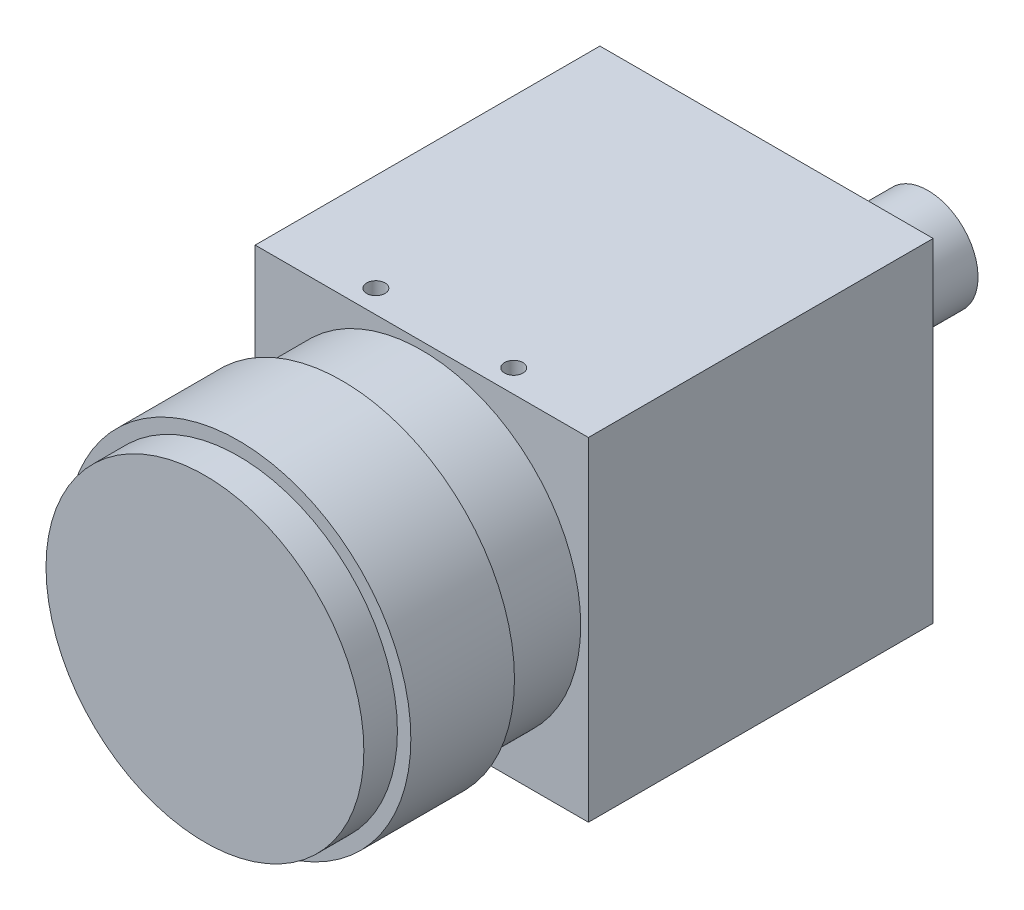
from build123d import *

# Parameters (mm, degrees)
SKETCH1_W                 = 29
SKETCH1_H                 = 29
BOSS_EXTRUDE1_DEPTH       = 30
SKETCH2_R                 = 13.8303
BOSS_EXTRUDE2_DEPTH       = 18.8722
M2X0_4_TAPPED_HOLE1_D     = 1.6
M2X0_4_TAPPED_HOLE1_DEPTH = 8.31088
M2X0_4_TAPPED_HOLE1_TIP   = 0.480688495
M2X0_4_TAPPED_HOLE2_D     = 1.6
M2X0_4_TAPPED_HOLE2_DEPTH = 8.31088
M2X0_4_TAPPED_HOLE2_TIP   = 0.480688495
M3X0_5_TAPPED_HOLE1_D     = 2.5
M3X0_5_TAPPED_HOLE1_DEPTH = 7.50062
M3X0_5_TAPPED_HOLE1_TIP   = 0.751075774
BOSS_EXTRUDE4_DEPTH       = 3.937
SKETCH15_7_R              = 4.3561
BOSS_EXTRUDE5_DEPTH       = 6.4516
BOSS_EXTRUDE6_START       = 6.9342
SKETCH2_5_R               = 14.9987
BOSS_EXTRUDE6_DEPTH       = 9.017


with BuildPart() as part:
    # Sketch1 → Boss-Extrude1 (new body)
    with BuildSketch(Plane.XY):
        with Locations((14.5, 14.5)):
            Rectangle(SKETCH1_W, SKETCH1_H)
    extrude(amount=BOSS_EXTRUDE1_DEPTH)

    # Sketch2 → Boss-Extrude2 (add)
    with BuildSketch(Plane.XY.offset(30)):
        with Locations((14.5, 14.5)):
            Circle(SKETCH2_R)
    extrude(amount=BOSS_EXTRUDE2_DEPTH)

    # M2x0.4 Tapped Hole1
    with Locations(Plane(origin=(0, 0, 0), x_dir=(-1, 0, 0), z_dir=(0, -1, 0))):
        with Locations((-20.5, -3.5), (-20.5, -25.5), (-8.5, -3.5), (-8.5, -25.5)):
            Hole(M2X0_4_TAPPED_HOLE1_D / 2, depth=M2X0_4_TAPPED_HOLE1_DEPTH)
            with Locations((0, 0, -(M2X0_4_TAPPED_HOLE1_DEPTH + M2X0_4_TAPPED_HOLE1_TIP / 2))):  # 118° drill point
                Cone(0, M2X0_4_TAPPED_HOLE1_D / 2, M2X0_4_TAPPED_HOLE1_TIP, mode=Mode.SUBTRACT)

    # M2x0.4 Tapped Hole2
    with Locations(Plane(origin=(0, 29, 0), x_dir=(1, 0, 0), z_dir=(0, 1, 0))):
        with Locations((20.5, -28), (8.5, -28)):
            Hole(M2X0_4_TAPPED_HOLE2_D / 2, depth=M2X0_4_TAPPED_HOLE2_DEPTH)
            with Locations((0, 0, -(M2X0_4_TAPPED_HOLE2_DEPTH + M2X0_4_TAPPED_HOLE2_TIP / 2))):  # 118° drill point
                Cone(0, M2X0_4_TAPPED_HOLE2_D / 2, M2X0_4_TAPPED_HOLE2_TIP, mode=Mode.SUBTRACT)

    # M3x0.5 Tapped Hole1
    with Locations(Plane(origin=(0, 0, 0), x_dir=(-1, 0, 0), z_dir=(0, -1, 0))):
        with Locations((-14.5, -3.5), (-4.5, -27), (-24.5, -27)):
            Hole(M3X0_5_TAPPED_HOLE1_D / 2, depth=M3X0_5_TAPPED_HOLE1_DEPTH)
            with Locations((0, 0, -(M3X0_5_TAPPED_HOLE1_DEPTH + M3X0_5_TAPPED_HOLE1_TIP / 2))):  # 118° drill point
                Cone(0, M3X0_5_TAPPED_HOLE1_D / 2, M3X0_5_TAPPED_HOLE1_TIP, mode=Mode.SUBTRACT)

    # Sketch15 → Boss-Extrude4 (add)
    with BuildSketch(Plane(origin=(0, 0, 0), x_dir=(-1, 0, 0), z_dir=(0, 0, -1))):
        with BuildLine():
            Line((-5.1308, 18.034), (-19.572374024, 18.034))
            ThreePointArc((-19.572374024, 18.034), (-23.423695495, 25.732674505), (-22.098, 17.2271))
            Line((-22.098, 17.2271), (-22.098, 3.048))
            Line((-22.098, 3.048), (-5.1308, 3.048))
            Line((-5.1308, 3.048), (-5.1308, 18.034))
        make_face()
    extrude(amount=BOSS_EXTRUDE4_DEPTH)

    # Sketch15_7 → Boss-Extrude5 (add)
    with BuildSketch(Plane(origin=(0, 0, 0), x_dir=(-1, 0, 0), z_dir=(0, 0, -1))):
        with Locations((-22.098, 21.5832)):
            Circle(SKETCH15_7_R)
    extrude(amount=BOSS_EXTRUDE5_DEPTH)

    # Sketch2_5 → Boss-Extrude6 (add)
    with BuildSketch(Plane.XY.offset(30).offset(BOSS_EXTRUDE6_START)):
        with Locations((14.5, 14.5)):
            Circle(SKETCH2_5_R)
    extrude(amount=BOSS_EXTRUDE6_DEPTH)


solid = part.part
